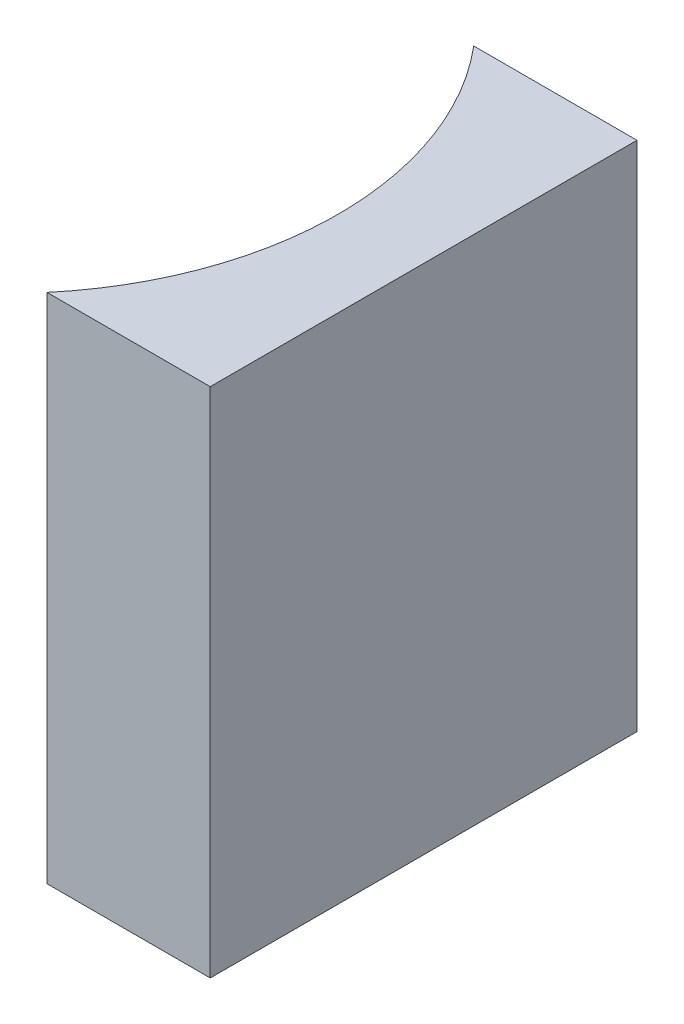
from build123d import *

# Parameters (mm, degrees)
EXTRUDE_1_DEPTH = 12


with BuildPart() as part:
    # 草图1 → 凸台-拉伸1 (new body)
    with BuildSketch(Plane(origin=(0, 0, 0), x_dir=(1, 0, 0), z_dir=(0, 1, 0))):
        with BuildLine():
            Line((0, 0), (0, -10))
            Line((0, -10), (-3.825558156, -10))
            ThreePointArc((-3.825558156, -10), (-2, -5), (-3.825558156, 0))
            Line((-3.825558156, 0), (0, 0))
        make_face()
    extrude(amount=EXTRUDE_1_DEPTH)


solid = part.part
